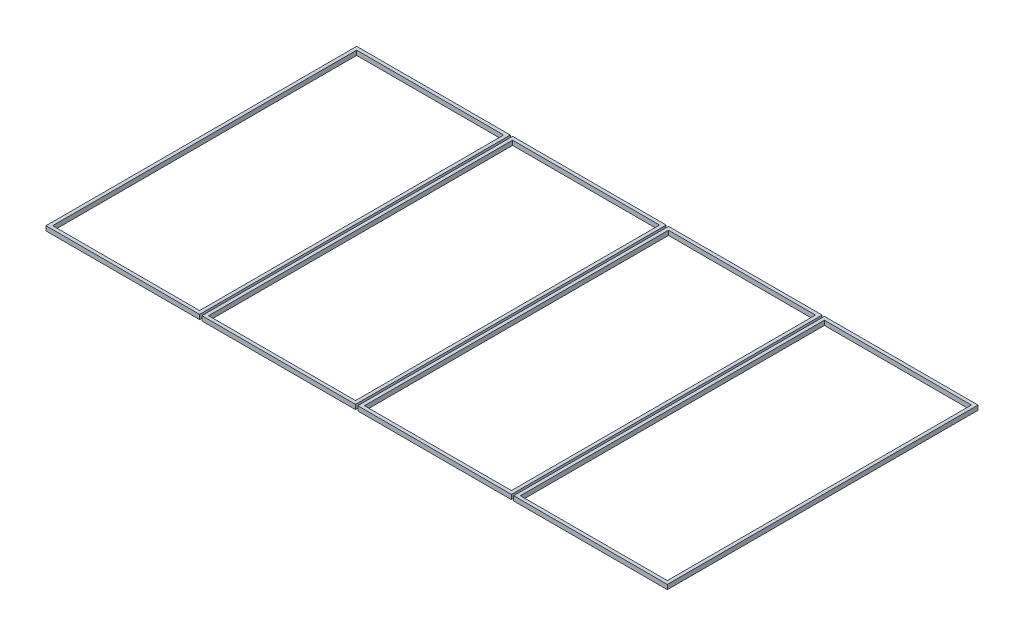
from build123d import *

# Parameters (mm, degrees)
SKETCH1_W            = 577.25
SKETCH1_H            = 1194
BOSS_EXTRU_1_DEPTH   = 18
BOSS_EXTRU_1_2_DEPTH = 18
BOSS_EXTRU_1_3_DEPTH = 18
BOSS_EXTRU_1_4_DEPTH = 18


with BuildPart() as part:
    # Sketch1 → Boss.-Extru.1 (new body)
    with BuildSketch(Plane(origin=(0, 0, 0), x_dir=(1, 0, 0), z_dir=(0, 1, 0))):
        Polygon((0, 0), (0, 1220), (603.25, 1220), (603.25, 0), (590.25, 0), (13, 0), align=None)
        with Locations((301.625, 610)):
            Rectangle(SKETCH1_W, SKETCH1_H, mode=Mode.SUBTRACT)
    extrude(amount=BOSS_EXTRU_1_DEPTH)


with BuildPart() as body_2:
    # Sketch1 → Boss.-Extru.1 2 (new body)
    with BuildSketch(Plane(origin=(0, 0, 0), x_dir=(1, 0, 0), z_dir=(0, 1, 0))):
        Polygon((2440, 0), (2440, 1220), (1836.75, 1220), (1836.75, 0), (1849.75, 0), (2427, 0), align=None)
        with Locations((2138.375, 610)):
            Rectangle(SKETCH1_W, SKETCH1_H, mode=Mode.SUBTRACT)
    extrude(amount=BOSS_EXTRU_1_2_DEPTH)


with BuildPart() as body_3:
    # Sketch1 → Boss.-Extru.1 3 (new body)
    with BuildSketch(Plane(origin=(0, 0, 0), x_dir=(1, 0, 0), z_dir=(0, 1, 0))):
        Polygon((625.25, 0), (1202.5, 0), (1215.5, 0), (1215.5, 1220), (612.25, 1220), (612.25, 0), align=None)
        with Locations((913.875, 610)):
            Rectangle(SKETCH1_W, SKETCH1_H, mode=Mode.SUBTRACT)
    extrude(amount=BOSS_EXTRU_1_3_DEPTH)


with BuildPart() as body_4:
    # Sketch1 → Boss.-Extru.1 4 (new body)
    with BuildSketch(Plane(origin=(0, 0, 0), x_dir=(1, 0, 0), z_dir=(0, 1, 0))):
        Polygon((1237.5, 0), (1814.75, 0), (1827.75, 0), (1827.75, 1220), (1224.5, 1220), (1224.5, 0), align=None)
        with Locations((1526.125, 610)):
            Rectangle(SKETCH1_W, SKETCH1_H, mode=Mode.SUBTRACT)
    extrude(amount=BOSS_EXTRU_1_4_DEPTH)


solid = Compound([part.part, body_2.part, body_3.part, body_4.part])
